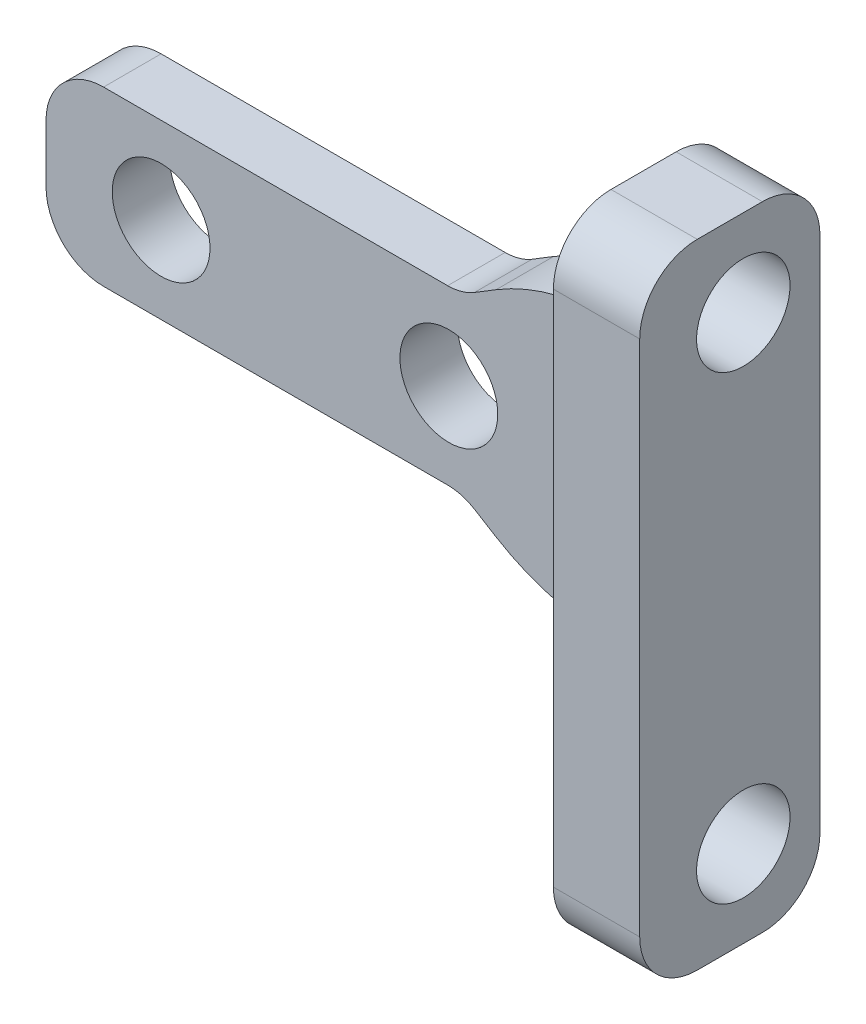
from build123d import *

# Parameters (mm, degrees)
BOSS_EXTRUDE1_DEPTH  = 2
SKETCH1_3_W          = 3
SKETCH1_3_H          = 22
BOSS_EXTRUDE2_DEPTH  = 6.265
M3_CLEARANCE_HOLE1_D = 3.4
FILLET1_R            = 2
SKETCH6_R            = 1.625
CUT_EXTRUDE1_DEPTH   = 7.5
FILLET2_R            = 1
CHAMFER1_SIZE        = 0.5


with BuildPart() as part:
    # Sketch1 → Boss-Extrude1 (new body)
    with BuildSketch(Plane.XY):
        with BuildLine():
            Line((9.958333406, 3), (-4, 3))
            Line((-4, 3), (-4, -3))
            Line((-4, -3), (9.958333406, -3))
            ThreePointArc((9.958333406, -3), (10.44298868, -3.066896425), (10.891399918, -3.262582978))
            Line((10.891399918, -3.262582978), (11.642445292, -3.721657662))
            ThreePointArc((11.642445292, -3.721657662), (13.535102515, -4.547612803), (15.580738809, -4.829969693))
            Line((15.580738809, -4.829969693), (17.9, -4.829969693))
            Line((17.9, -4.829969693), (17.9, 4.829969693))
            Line((17.9, 4.829969693), (15.580738809, 4.829969693))
            ThreePointArc((15.580738809, 4.829969693), (13.535102515, 4.547612803), (11.642445292, 3.721657662))
            Line((11.642445292, 3.721657662), (10.891399918, 3.262582978))
            ThreePointArc((10.891399918, 3.262582978), (10.44298868, 3.066896425), (9.958333406, 3))
        make_face()
        Polygon((17.9, 11), (17.9, 4.829969693), (17.9, -4.829969693), (17.9, -11), (20.9, -11), (20.9, 11), align=None)
    extrude(amount=BOSS_EXTRUDE1_DEPTH)

    # Sketch1_3 → Boss-Extrude2 (add)
    with BuildSketch(Plane.XY):
        with Locations((19.4, 0)):
            Rectangle(SKETCH1_3_W, SKETCH1_3_H)
    extrude(amount=BOSS_EXTRUDE2_DEPTH)

    # M3 Clearance Hole1 (through all)
    with Locations(Plane.XY.offset(2)):
        with Locations((0, 0), (10, 0)):
            Hole(M3_CLEARANCE_HOLE1_D / 2)

    # Fillet1
    fillet1_edges = [part.edges().sort_by_distance(p)[0] for p in [
        (19.4, 11, 0),
        (19.4, -11, 0),
        (-4, -3, 1),
        (-4, 3, 1),
        (19.4, -11, 6.265),
        (19.4, 11, 6.265),
    ]]
    fillet(fillet1_edges, radius=FILLET1_R)

    # Sketch6 → Cut-Extrude1 (cut)
    with BuildSketch(Plane(origin=(20.9, 0, 0), x_dir=(0, 0, -1), z_dir=(1, 0, 0))):
        with Locations((-2.665, -8)):
            Circle(SKETCH6_R)
        with Locations((-2.665, 8)):
            Circle(SKETCH6_R)
    extrude(amount=-CUT_EXTRUDE1_DEPTH, mode=Mode.SUBTRACT)

    # Fillet2
    fillet2_edges = [part.edges().sort_by_distance(p)[0] for p in [
        (17.9, 0, 2),
    ]]
    fillet(fillet2_edges, radius=FILLET2_R)

    # Chamfer1
    chamfer1_edges = [part.edges().sort_by_distance(p)[0] for p in [
        (17.9, 4.829969693, 1),
        (17.9, -4.829969693, 1),
    ]]
    chamfer(chamfer1_edges, length=CHAMFER1_SIZE)


solid = part.part
